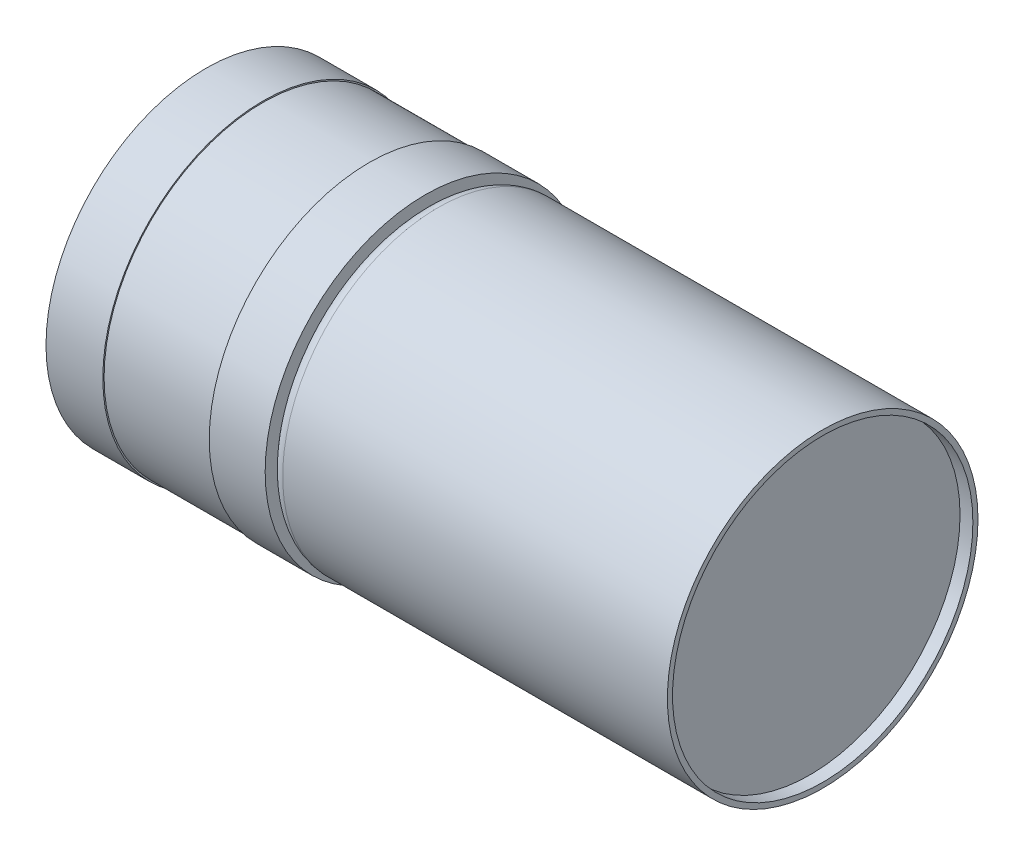
from build123d import *

# Parameters (mm, degrees)
SKETCH1_R           = 12.11
BOSS_EXTRUDE1_DEPTH = 31
FILLET1_R           = 1
SKETCH2_R           = 11.71
CUT_EXTRUDE1_DEPTH  = 1
SKETCH3_R           = 12.475
BOSS_EXTRUDE2_DEPTH = 4.36
SKETCH4_R           = 12.375
BOSS_EXTRUDE3_DEPTH = 8.3
SKETCH5_R           = 12.475
BOSS_EXTRUDE4_DEPTH = 4.43
SKETCH6_R           = 1.4
CUT_EXTRUDE2_DEPTH  = 6


with BuildPart() as part:
    # Sketch1 → Boss-Extrude1 (new body)
    with BuildSketch(Plane(origin=(0, 0, 0), x_dir=(0, 0, -1), z_dir=(1, 0, 0))):
        Circle(SKETCH1_R)
    extrude(amount=BOSS_EXTRUDE1_DEPTH)

    # Fillet1
    fillet1_edges = [part.edges().sort_by_distance(p)[0] for p in [
        (0, 0, 12.11),
    ]]
    fillet(fillet1_edges, radius=FILLET1_R)

    # Sketch2 → Cut-Extrude1 (cut)
    with BuildSketch(Plane(origin=(31, 0, 0), x_dir=(0, 0, -1), z_dir=(1, 0, 0))):
        Circle(SKETCH2_R)
    extrude(amount=-CUT_EXTRUDE1_DEPTH, mode=Mode.SUBTRACT)

    # Sketch3 → Boss-Extrude2 (add)
    with BuildSketch(Plane.ZY):
        Circle(SKETCH3_R)
    extrude(amount=BOSS_EXTRUDE2_DEPTH)

    # Sketch4 → Boss-Extrude3 (add)
    with BuildSketch(Plane.ZY.offset(4.36)):
        Circle(SKETCH4_R)
    extrude(amount=BOSS_EXTRUDE3_DEPTH)

    # Sketch5 → Boss-Extrude4 (add)
    with BuildSketch(Plane.ZY.offset(12.66)):
        Circle(SKETCH5_R)
    extrude(amount=BOSS_EXTRUDE4_DEPTH)

    # Sketch6 → Cut-Extrude2 (cut)
    with BuildSketch(Plane.ZY.offset(17.09)):
        with Locations((0, 8.5)):
            Circle(SKETCH6_R)
        with Locations((0, -8.5)):
            Circle(SKETCH6_R)
    extrude(amount=-CUT_EXTRUDE2_DEPTH, mode=Mode.SUBTRACT)


solid = part.part
